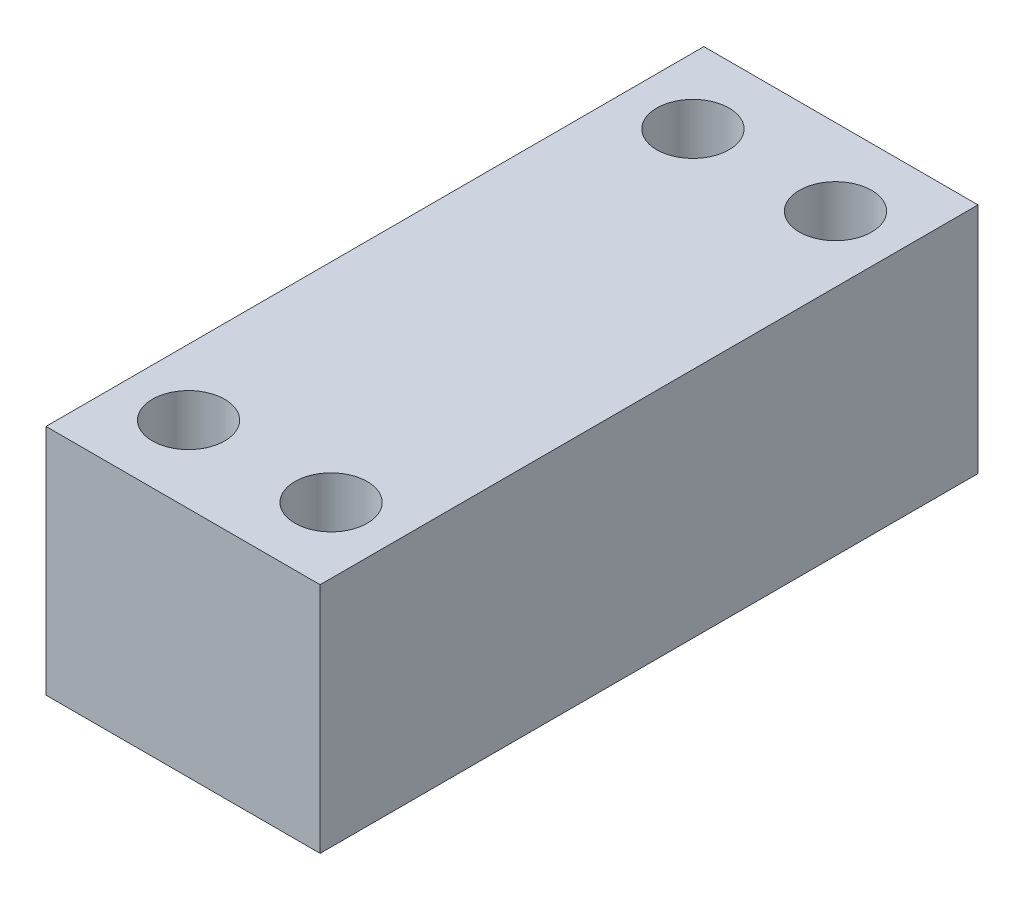
from build123d import *

# Parameters (mm, degrees)
SKETCH1_W           = 25
SKETCH1_H           = 60
SKETCH1_R           = 3.3
BOSS_EXTRUDE1_DEPTH = 21.22424


with BuildPart() as part:
    # Sketch1 → Boss-Extrude1 (new body)
    with BuildSketch(Plane(origin=(0, 0, 0), x_dir=(1, 0, 0), z_dir=(0, 1, 0))):
        with Locations((12.5, 0)):
            Rectangle(SKETCH1_W, SKETCH1_H)
        with Locations((6, 23)):
            Circle(SKETCH1_R, mode=Mode.SUBTRACT)
        with Locations((19, 23)):
            Circle(SKETCH1_R, mode=Mode.SUBTRACT)
        with Locations((19, -23)):
            Circle(SKETCH1_R, mode=Mode.SUBTRACT)
        with Locations((6, -23)):
            Circle(SKETCH1_R, mode=Mode.SUBTRACT)
    extrude(amount=BOSS_EXTRUDE1_DEPTH)


solid = part.part
